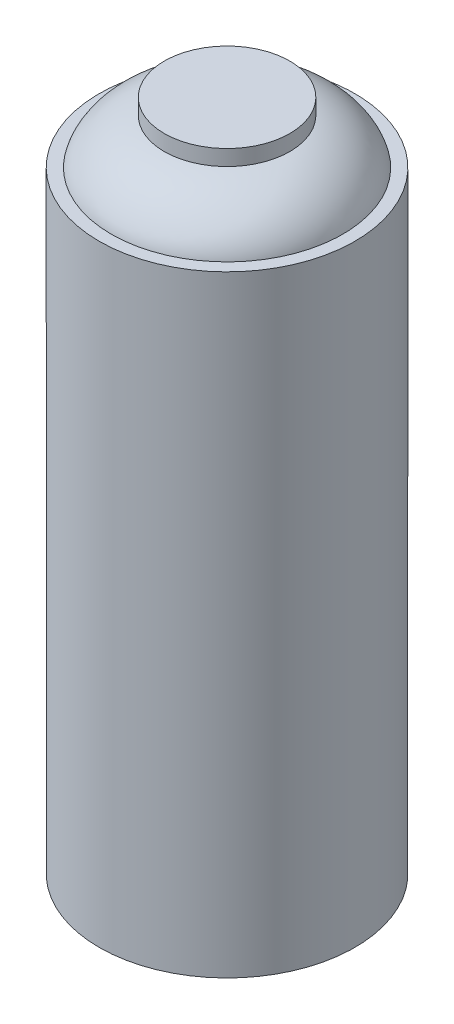
from build123d import *


with BuildPart() as part:
    # Sketch1 → Revolve1 (revolve)
    with BuildSketch(Plane.XY):
        with BuildLine():
            Line((0, 102.290424395), (0, -64.226907383))
            ThreePointArc((0, -64.226907383), (16.90585936, -66.043303148), (33.04, -71.409575605))
            Line((33.04, -71.409575605), (33.04, 86.590424395))
            Line((33.04, 86.590424395), (29.9, 86.590424395))
            add(Edge.make_bspline(
                [(29.9, 86.590424395), (28.948018921, 91.051860909), (23.931212043, 96.617268194), (16.225, 98.250424395)],
                knots=[0, 0, 0, 0, 1, 1, 1, 1], degree=3))
            Line((16.225, 98.250424395), (16.225, 102.290424395))
            Line((16.225, 102.290424395), (0, 102.290424395))
        make_face()
    revolve(axis=Axis((0, 102.290424395, 0), (0, -1, 0)))


solid = part.part
